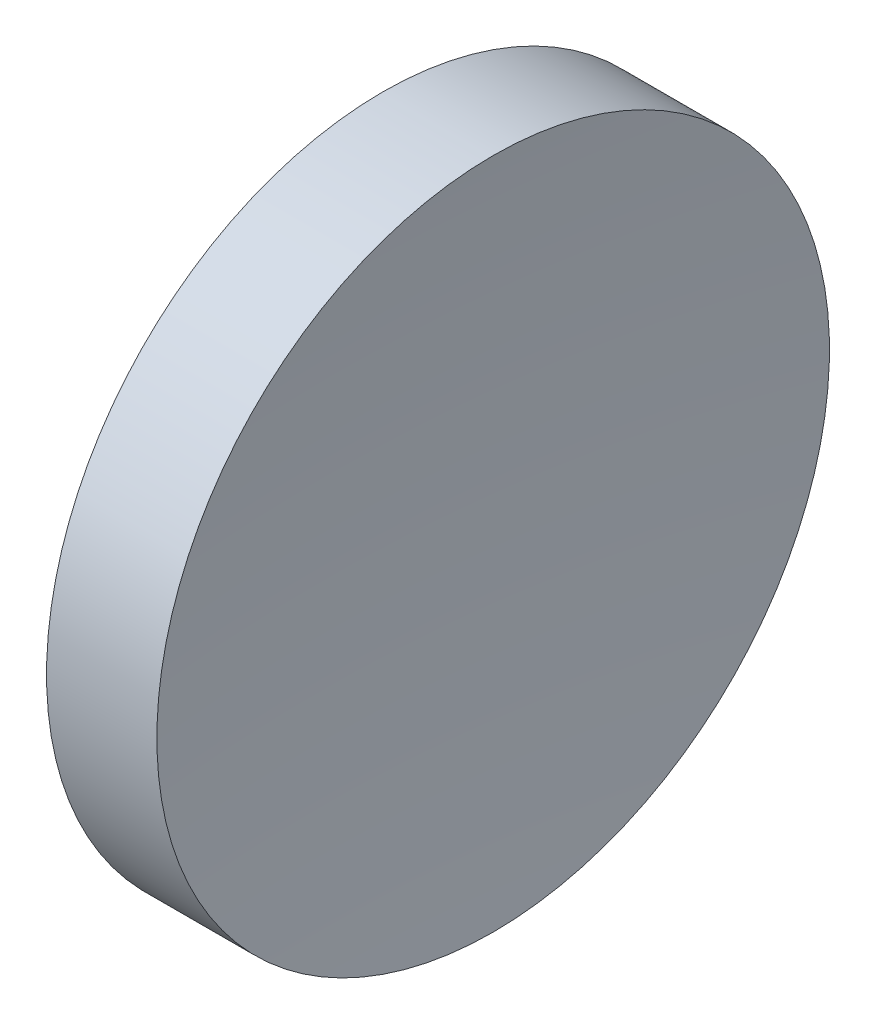
from build123d import *


with BuildPart() as part:
    # 草图1 → 旋转1 (revolve)
    with BuildSketch(Plane.XY):
        with BuildLine():
            Line((64.195211122, 38.858420235), (62.145049084, 38.858420235))
            ThreePointArc((62.145049084, 38.858420235), (61.516771193, 35.761448186), (61.306096742, 32.608420235))
            Line((61.306096742, 32.608420235), (63.906096742, 32.608420235))
            ThreePointArc((63.906096742, 32.608420235), (63.978413961, 35.736761934), (64.195211122, 38.858420235))
        make_face()
    revolve(axis=Axis((57.972245649, 32.608420235, 0), (1, 0, 0)))


solid = part.part
